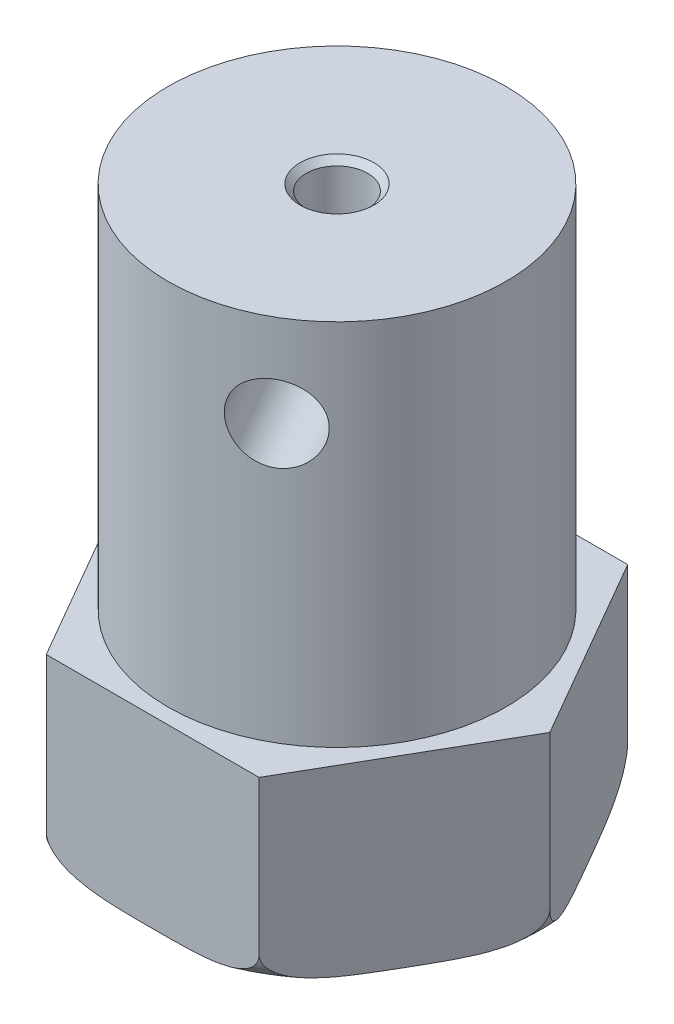
from build123d import *

# Parameters (mm, degrees)
SKETCH1_R                = 2
BASE_DEPTH               = 6
SKETCH2_R                = 5.5
SHAFT_HOLDING_BODY_DEPTH = 12
M3X0_5_1_D               = 2.5
SKETCH13_R               = 1
SHAFT_HOLE_DEPTH         = 19.0000001
SH_C_SIZE                = 0.2


with BuildPart() as part:
    # Sketch1 → BASE (new body)
    with BuildSketch(Plane(origin=(0, 0, 0), x_dir=(1, 0, 0), z_dir=(0, 1, 0))):
        Polygon((3.464101615, -6), (6.92820323, 0), (3.464101615, 6), (-3.464101615, 6), (-6.92820323, 0), (-3.464101615, -6), align=None)
        Circle(SKETCH1_R, mode=Mode.SUBTRACT)
    extrude(amount=BASE_DEPTH)

    # Sketch2 → SHAFT HOLDING BODY (add)
    with BuildSketch(Plane(origin=(0, 6, 0), x_dir=(1, 0, 0), z_dir=(0, 1, 0))):
        Circle(SKETCH2_R)
    extrude(amount=SHAFT_HOLDING_BODY_DEPTH)

    # M3x0.5 螺纹孔1 (through all)
    with Locations(Plane(origin=(2.75, 6, 4.763139721), x_dir=(0.866025404, 0, -0.5), z_dir=(0.5, 0, 0.866025404))):
        with Locations((0, 9)):
            Hole(M3X0_5_1_D / 2)

    # Sketch9 → BASE CHAMFER RELIEF (revolve, cut)
    with BuildSketch(Plane.XY):
        with BuildLine():
            Line((-6.92820323, 1), (-6.92820323, 0))
            Line((-6.92820323, 0), (-5.92820323, 0))
            ThreePointArc((-5.92820323, 0), (-6.635310011, 0.292893219), (-6.92820323, 1))
        make_face()
    revolve(axis=Axis((0, 22.106901259, 0), (0, -1, 0)), mode=Mode.SUBTRACT)

    # Sketch13 → SHAFT HOLE (cut, through all)
    with BuildSketch(Plane(origin=(0, 18, 0), x_dir=(1, 0, 0), z_dir=(0, 1, 0))):
        Circle(SKETCH13_R)
    extrude(amount=-SHAFT_HOLE_DEPTH, mode=Mode.SUBTRACT)

    # SH C
    sh_c_edges = [part.edges().sort_by_distance(p)[0] for p in [
        (-1, 18, 0),
    ]]
    chamfer(sh_c_edges, length=SH_C_SIZE)


solid = part.part
